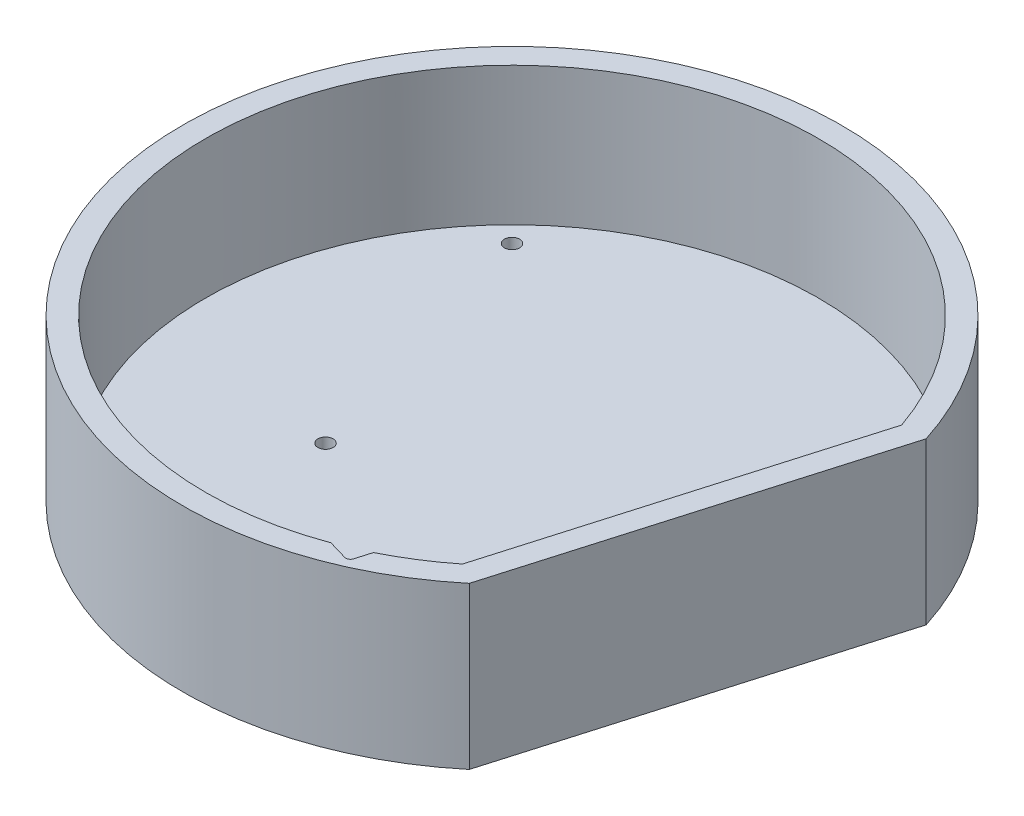
from build123d import *

# Parameters (mm, degrees)
BOSS_EXTRUDE1_DEPTH = 5
SKETCH2_R           = 1.65
CUT_EXTRUDE1_DEPTH  = 6
BOSS_EXTRUDE3_DEPTH = 30
CUT_EXTRUDE2_DEPTH  = 15
FILLET1_R           = 1
SKETCH5_R           = 1.65
CUT_EXTRUDE3_DEPTH  = 6


with BuildPart() as part:
    # Sketch1 → Boss-Extrude1 (new body)
    with BuildSketch(Plane(origin=(0, 0, 0), x_dir=(1, 0, 0), z_dir=(0, 1, 0))):
        with BuildLine():
            Line((45.736375855, -55.017005995), (68.149505263, 21.779163377))
            ThreePointArc((68.149505263, 21.779163377), (-68.679774221, 20.044341793), (45.736375855, -55.017005995))
        make_face()
    extrude(amount=BOSS_EXTRUDE1_DEPTH)

    # Sketch2 → Cut-Extrude1 (cut, through all)
    with BuildSketch(Plane(origin=(0, 5, 0), x_dir=(1, 0, 0), z_dir=(0, 1, 0))):
        with Locations((43.522422382, 43.522422382)):
            Circle(SKETCH2_R)
        with Locations((-43.522422382, -43.522422382)):
            Circle(SKETCH2_R)
        with Locations((-43.522422382, 43.522422382)):
            Circle(SKETCH2_R)
        with Locations((3.221278107, -61.465647864)):
            Circle(SKETCH2_R)
    extrude(amount=-CUT_EXTRUDE1_DEPTH, mode=Mode.SUBTRACT)

    # Sketch3 → Boss-Extrude3 (add)
    with BuildSketch(Plane(origin=(0, 5, 0), x_dir=(1, 0, 0), z_dir=(0, 1, 0))):
        with BuildLine():
            Line((45.736375855, -55.017005995), (68.149505263, 21.779163377))
            ThreePointArc((68.149505263, 21.779163377), (-68.679774221, 20.044341793), (45.736375855, -55.017005995))
        make_face()
        with BuildLine():
            Line((41.373300987, -52.119928918), (62.91305896, 21.683727477))
            ThreePointArc((62.91305896, 21.683727477), (-63.880013635, 18.643521205), (41.373300987, -52.119928918))
        make_face(mode=Mode.SUBTRACT)
    extrude(amount=BOSS_EXTRUDE3_DEPTH)

    # Sketch4 → Cut-Extrude2 (cut)
    with BuildSketch(Plane(origin=(-10.769878987, 0, 36.901828197), x_dir=(0, -1, 0), z_dir=(0.280164118, 0, -0.959952117))):
        with BuildLine():
            Line((-19, -45.06852177), (-35, -45.06852177))
            ThreePointArc((-35, -45.06852177), (-38.5, -41.56852177), (-35, -38.06852177))
            Line((-35, -38.06852177), (-19, -38.06852177))
            ThreePointArc((-19, -38.06852177), (-15.5, -41.56852177), (-19, -45.06852177))
        make_face()
    extrude(amount=-CUT_EXTRUDE2_DEPTH, mode=Mode.SUBTRACT)

    # Fillet1
    fillet1_edges = [part.edges().sort_by_distance(p)[0] for p in [
        (26.529321315, 15.921147738, 63.413460481),
        (28.291282139, 27, 63.927692588),
    ]]
    fillet(fillet1_edges, radius=FILLET1_R)

    # Sketch5 → Cut-Extrude3 (cut, through all)
    with BuildSketch(Plane(origin=(0, 5, 0), x_dir=(1, 0, 0), z_dir=(0, 1, 0))):
        with Locations((26.569138232, -29.673397669)):
            Circle(SKETCH5_R)
        with Locations((-26.228228211, -14.264371202)):
            Circle(SKETCH5_R)
    extrude(amount=-CUT_EXTRUDE3_DEPTH, mode=Mode.SUBTRACT)


solid = part.part
